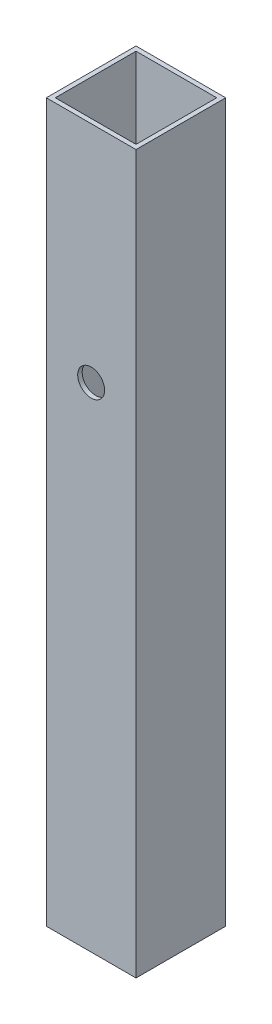
from build123d import *

# Parameters (mm, degrees)
SKETCH_1_W          = 20
SKETCH_1_H          = 20
SKETCH_1_W_2        = 18
SKETCH_1_H_2        = 18
EXTRUDE_1_DEPTH     = 140
SKETCH_2_W          = 20
SKETCH_2_H          = 20
EXTRUDE_2_DEPTH     = 20
SKETCH_3_R          = 3
CUT_EXTRUDE_1_DEPTH = 2


with BuildPart() as part:
    # 草图1 → 凸台-拉伸1 (new body)
    with BuildSketch(Plane(origin=(0, 0, 0), x_dir=(1, 0, 0), z_dir=(0, 1, 0))):
        Rectangle(SKETCH_1_W, SKETCH_1_H)
        Rectangle(SKETCH_1_W_2, SKETCH_1_H_2, mode=Mode.SUBTRACT)
    extrude(amount=EXTRUDE_1_DEPTH)

    # 草图2 → 凸台-拉伸2 (add)
    with BuildSketch(Plane.XZ):
        Rectangle(SKETCH_2_W, SKETCH_2_H)
    extrude(amount=EXTRUDE_2_DEPTH)

    # 草图3 → 切除-拉伸1 (cut)
    with BuildSketch(Plane.XY.offset(10)):
        with Locations((0, 90)):
            Circle(SKETCH_3_R)
    extrude(amount=-CUT_EXTRUDE_1_DEPTH, mode=Mode.SUBTRACT)


solid = part.part
